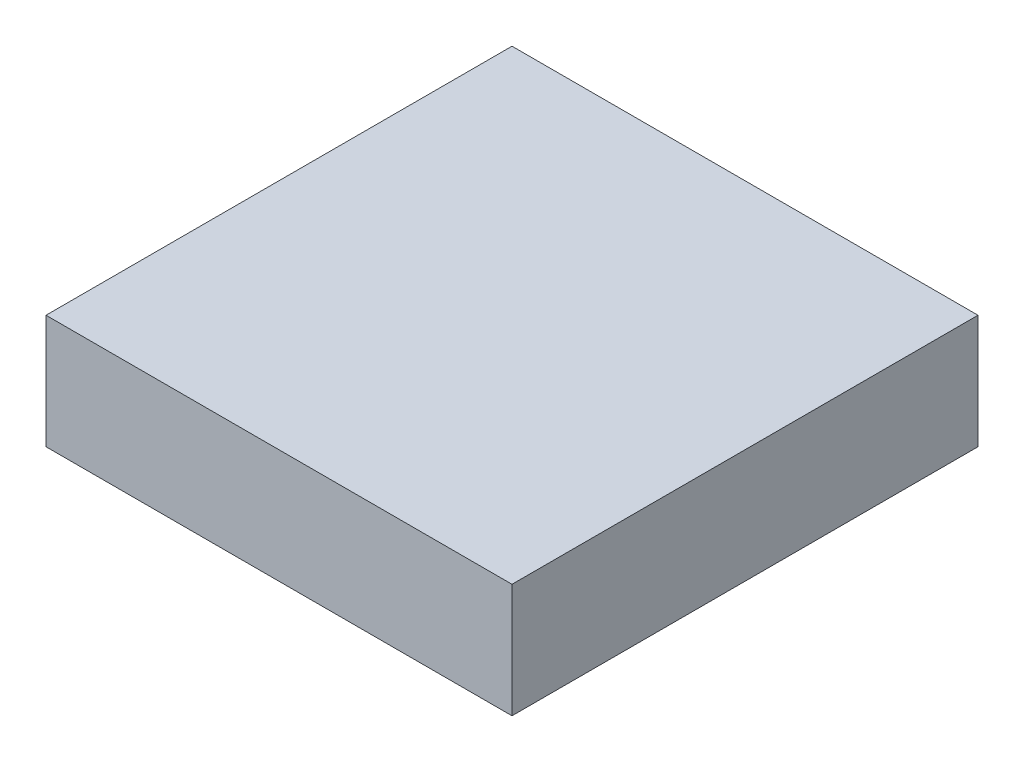
from build123d import *

# Parameters (mm, degrees)
SKETCH2_W           = 9
SKETCH2_H           = 9
BOSS_EXTRUDE1_DEPTH = 2.2


with BuildPart() as part:
    # Sketch2 → Boss-Extrude1 (new body)
    with BuildSketch(Plane(origin=(0, 99.401531763, -4.345e-06), x_dir=(-1, 0, 0), z_dir=(0, -1, 4.4e-08))):
        with Locations((-40.91030477, -143.155151275)):
            Rectangle(SKETCH2_W, SKETCH2_H)
    extrude(amount=-BOSS_EXTRUDE1_DEPTH)


solid = part.part
